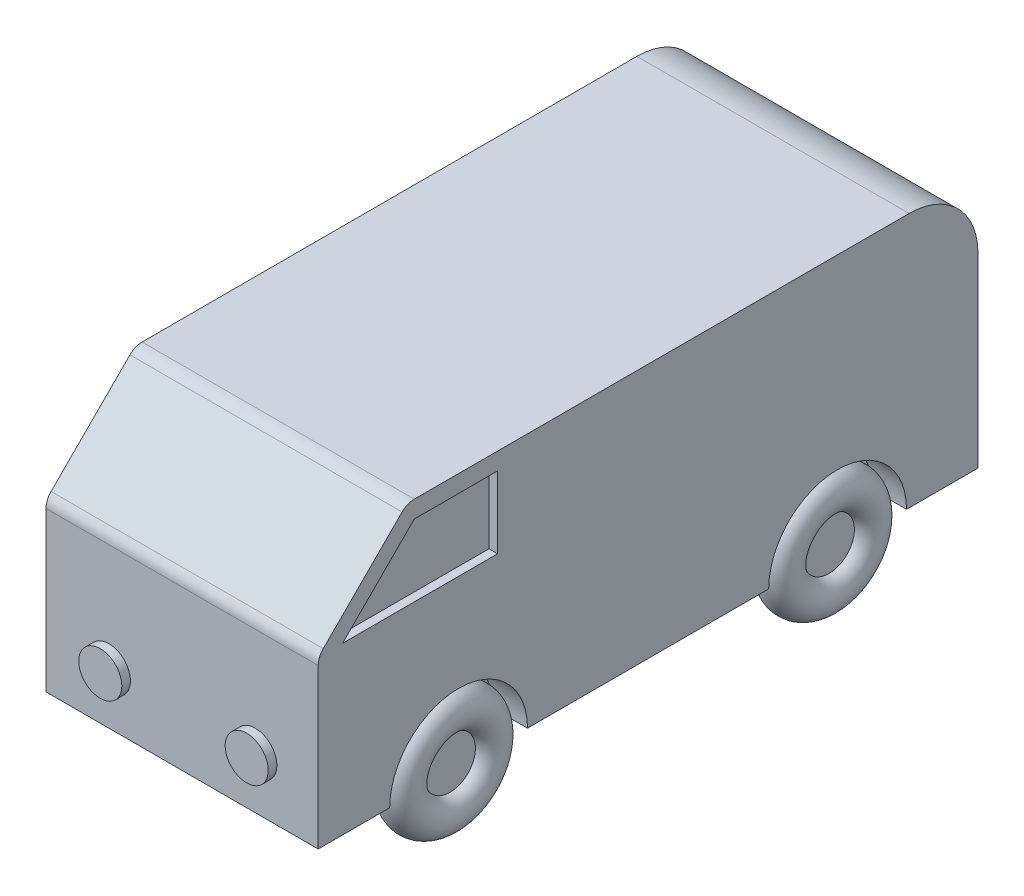
from build123d import *

# Parameters (mm, degrees)
BOSS_EXTRUDE1_DEPTH = 79
SKETCH2_R           = 12.5
BOSS_EXTRUDE2_DEPTH = 5
SKETCH3_R           = 40
CUT_EXTRUDE1_DEPTH  = 20
CUT_EXTRUDE2_DEPTH  = 5
CUT_EXTRUDE3_DEPTH  = 5
FILLET1_R           = 10
FILLET2_R           = 10


with BuildPart() as part:
    # Sketch1 → Boss-Extrude1 (new body, symmetric)
    with BuildSketch(Plane(origin=(0, 0, 0), x_dir=(0, 0, -1), z_dir=(1, 0, 0))):
        with BuildLine():
            Line((-191.5, 0), (0, 0))
            Line((0, 0), (191.5, 0))
            Line((191.5, 0), (191.5, 108))
            ThreePointArc((191.5, 108), (179.784271247, 136.284271247), (151.5, 148))
            Line((151.5, 148), (-139.86, 148))
            Line((-139.86, 148), (-191.5, 96.36))
            Line((-191.5, 96.36), (-191.5, 0))
        make_face()
    extrude(amount=BOSS_EXTRUDE1_DEPTH, both=True)

    # Sketch2 → Boss-Extrude2 (add)
    with BuildSketch(Plane.XY.offset(191.5)):
        with Locations(Location((-42.5, 30, 0), (0, 0, 90))):  # turned: the seam where the file's is
            Circle(SKETCH2_R)
        with Locations(Location((42.5, 30, 0), (0, 0, 90))):  # turned: the seam where the file's is
            Circle(SKETCH2_R)
    extrude(amount=BOSS_EXTRUDE2_DEPTH)

    # Sketch3 → Cut-Extrude1 (cut)
    with BuildSketch(Plane.ZY.offset(79)):
        with Locations((-110, 0)):
            Circle(SKETCH3_R)
        with Locations((110, 0)):
            Circle(SKETCH3_R)
    cut_extrude1 = extrude(amount=-CUT_EXTRUDE1_DEPTH, mode=Mode.SUBTRACT)

    # Mirror1: Cut-Extrude1 across plane
    add(cut_extrude1.mirror(Plane(origin=(0, 0, 0), x_dir=(0, 0, 1), z_dir=(1, 0, 0))), mode=Mode.SUBTRACT)

    # Sketch4 → Revolve1 (revolve)
    with BuildSketch(Plane(origin=(0, 0, 0), x_dir=(1, 0, 0), z_dir=(0, 1, 0))):
        with BuildLine():
            Line((-59, 110), (-59, 135))
            ThreePointArc((-59, 135), (-76.204836823, 144.082951062), (-74, 124.753049234))
            Line((-74, 124.753049234), (-74, 110))
            Line((-74, 110), (-59, 110))
        make_face()
    revolve1 = revolve(axis=Axis((-59, 0, -110), (-1, 0, 0)))

    # Mirror5: Revolve1 across plane
    add(revolve1.mirror(Plane.XY))

    # Mirror6: Revolve1 across plane
    add(revolve1.mirror(Plane(origin=(0, 0, 0), x_dir=(0, 0, 1), z_dir=(1, 0, 0))))

    # Mirror6 copy 1 sketch → Mirror6 copy 1 (revolve)
    with BuildSketch(Plane(origin=(0, 0, 0), x_dir=(-1, 0, 0), z_dir=(0, 1, 0))):
        with BuildLine():
            Line((-59, 110), (-59, 135))
            ThreePointArc((-59, 135), (-76.204836823, 144.082951062), (-74, 124.753049234))
            Line((-74, 124.753049234), (-74, 110))
            Line((-74, 110), (-59, 110))
        make_face()
    revolve(axis=Axis((59, 0, 110), (1, 0, 0)))

    # Sketch5 → Cut-Extrude2 (cut)
    with BuildSketch(Plane.ZY.offset(79)):
        Polygon((135.717864376, 138), (177.357864376, 96.36), (87.357864376, 96.36), (87.357864376, 138), align=None)
    extrude(amount=-CUT_EXTRUDE2_DEPTH, mode=Mode.SUBTRACT)

    # Sketch6 → Cut-Extrude3 (cut)
    with BuildSketch(Plane(origin=(79, 0, 0), x_dir=(0, 0, -1), z_dir=(1, 0, 0))):
        Polygon((-177.357864376, 96.36), (-135.717864376, 138), (-87.357864376, 138), (-87.357864376, 96.36), align=None)
    extrude(amount=-CUT_EXTRUDE3_DEPTH, mode=Mode.SUBTRACT)

    # Fillet1
    fillet1_edges = [part.edges().sort_by_distance(p)[0] for p in [
        (0, 96.36, 191.5),
    ]]
    fillet(fillet1_edges, radius=FILLET1_R)

    # Fillet2
    fillet2_edges = [part.edges().sort_by_distance(p)[0] for p in [
        (0, 148, 139.86),
    ]]
    fillet(fillet2_edges, radius=FILLET2_R)


solid = part.part
